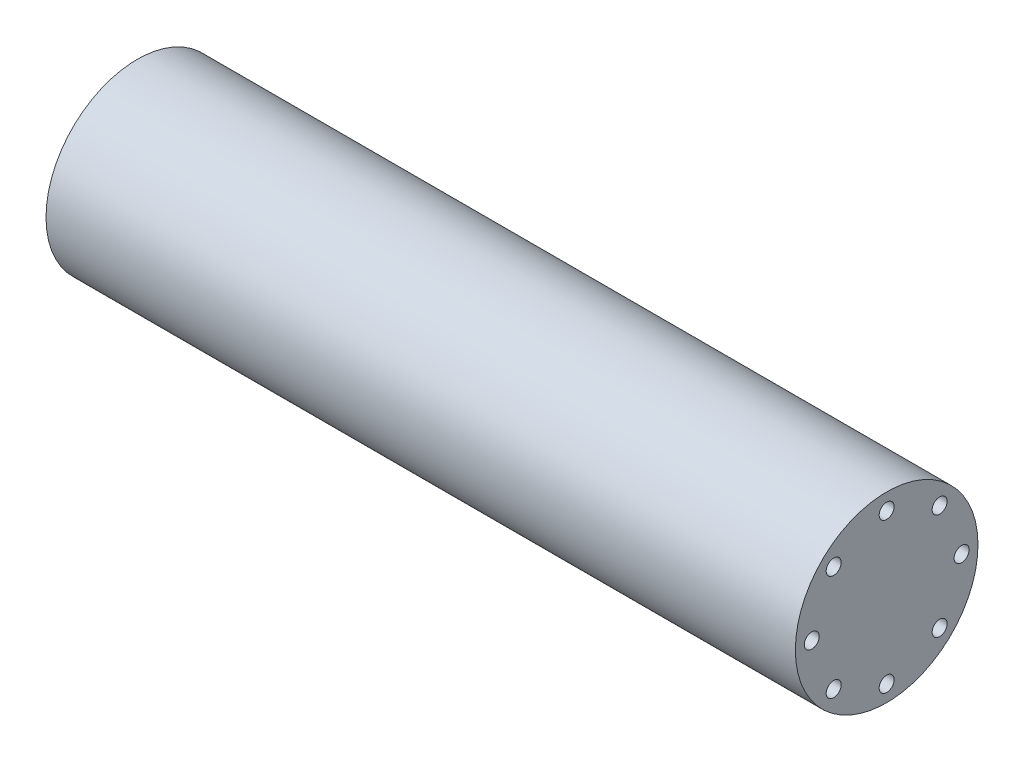
from build123d import *

# Parameters (mm, degrees)
SKETCH_1_W                  = 80
SKETCH_1_H                  = 9.75
HOLE_WIZARD_1_6_1_6_1_D     = 1.6
HOLE_WIZARD_1_6_1_6_1_DEPTH = 15.2
HOLE_WIZARD_1_6_1_6_1_TIP   = 0.480688495
HOLE_WIZARD_1_6_1_6_2_D     = 1.6
HOLE_WIZARD_1_6_1_6_2_DEPTH = 15.2
HOLE_WIZARD_1_6_1_6_2_TIP   = 0.480688495


with BuildPart() as part:
    # 스케치1 → 회전1 (revolve)
    with BuildSketch(Plane(origin=(0, 0, 0), x_dir=(-1, 0, 0), z_dir=(0, 0, -1))):
        with Locations((-40, 4.875)):
            Rectangle(SKETCH_1_W, SKETCH_1_H)
    revolve(axis=Axis((80, 0, 0), (-1, 0, 0)))

    # Ø1.6 (1.6) 지름 구멍1
    with Locations(Plane.ZY):
        with Locations((0, 8), (-5.656854249, 5.656854249), (-8, 0), (-5.656854249, -5.656854249), (0, -8), (5.656854249, -5.656854249), (8, 0), (5.656854249, 5.656854249)):
            Hole(HOLE_WIZARD_1_6_1_6_1_D / 2, depth=HOLE_WIZARD_1_6_1_6_1_DEPTH)
            with Locations((0, 0, -(HOLE_WIZARD_1_6_1_6_1_DEPTH + HOLE_WIZARD_1_6_1_6_1_TIP / 2))):  # 118° drill point
                Cone(0, HOLE_WIZARD_1_6_1_6_1_D / 2, HOLE_WIZARD_1_6_1_6_1_TIP, mode=Mode.SUBTRACT)

    # Ø1.6 (1.6) 지름 구멍2
    with Locations(Plane(origin=(80, 0, 0), x_dir=(0, 0, -1), z_dir=(1, 0, 0))):
        with Locations((0, 8), (5.656854249, 5.656854249), (8, 0), (5.656854249, -5.656854249), (0, -8), (-5.656854249, -5.656854249), (-8, 0), (-5.656854249, 5.656854249)):
            Hole(HOLE_WIZARD_1_6_1_6_2_D / 2, depth=HOLE_WIZARD_1_6_1_6_2_DEPTH)
            with Locations((0, 0, -(HOLE_WIZARD_1_6_1_6_2_DEPTH + HOLE_WIZARD_1_6_1_6_2_TIP / 2))):  # 118° drill point
                Cone(0, HOLE_WIZARD_1_6_1_6_2_D / 2, HOLE_WIZARD_1_6_1_6_2_TIP, mode=Mode.SUBTRACT)


solid = part.part
